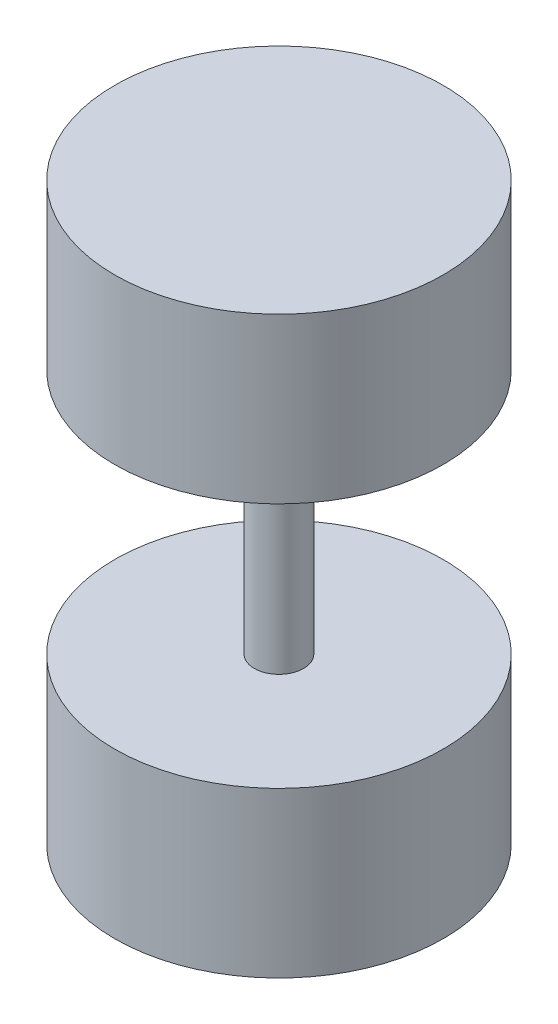
from build123d import *

# Parameters (mm, degrees)
SKETCH1_R           = 10
BOSS_EXTRUDE1_DEPTH = 10
SKETCH2_R           = 1.5
BOSS_EXTRUDE2_DEPTH = 15
CUT_EXTRUDE1_DEPTH  = 8
SKETCH4_R           = 10
BOSS_EXTRUDE3_DEPTH = 10


with BuildPart() as part:
    # Sketch1 → Boss-Extrude1 (new body)
    with BuildSketch(Plane(origin=(0, 0, 0), x_dir=(1, 0, 0), z_dir=(0, 1, 0))):
        Circle(SKETCH1_R)
    extrude(amount=BOSS_EXTRUDE1_DEPTH)

    # Sketch2 → Boss-Extrude2 (add)
    with BuildSketch(Plane(origin=(0, 10, 0), x_dir=(1, 0, 0), z_dir=(0, 1, 0))):
        Circle(SKETCH2_R)
    extrude(amount=BOSS_EXTRUDE2_DEPTH)

    # Sketch3 → Cut-Extrude1 (cut)
    with BuildSketch(Plane.XZ):
        Polygon((7, 0), (3.5, 6.062177826), (-3.5, 6.062177826), (-7, 0), (-3.5, -6.062177826), (3.5, -6.062177826), align=None)
    extrude(amount=-CUT_EXTRUDE1_DEPTH, mode=Mode.SUBTRACT)

    # Sketch4 → Boss-Extrude3 (add)
    with BuildSketch(Plane(origin=(0, 25, 0), x_dir=(1, 0, 0), z_dir=(0, 1, 0))):
        Circle(SKETCH4_R)
    extrude(amount=BOSS_EXTRUDE3_DEPTH)


solid = part.part
